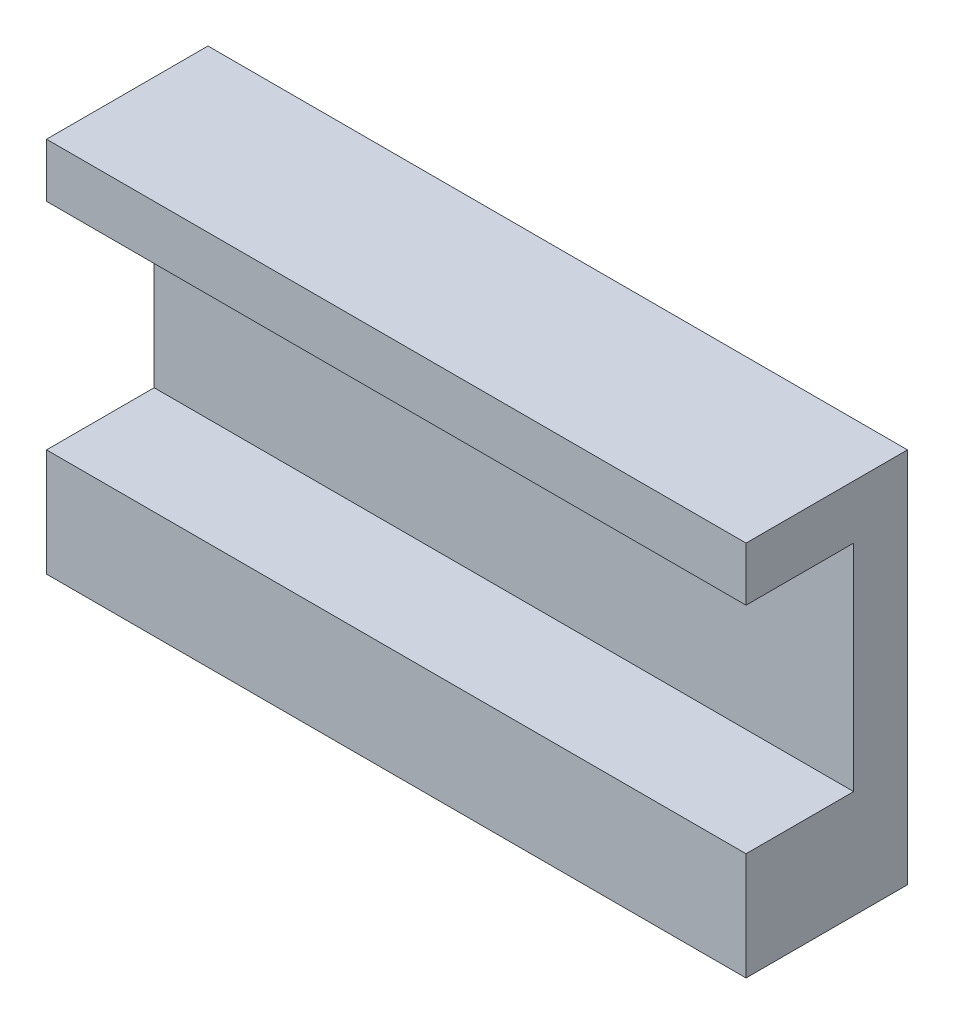
from build123d import *

# Parameters (mm, degrees)
SKETCH1_W           = 130
SKETCH1_H           = 70
BOSS_EXTRUDE1_DEPTH = 10
SKETCH2_W           = 130
SKETCH2_H           = 10
SKETCH2_H_2         = 20
BOSS_EXTRUDE2_DEPTH = 20


with BuildPart() as part:
    # Sketch1 → Boss-Extrude1 (new body)
    with BuildSketch(Plane.XY):
        with Locations((65, 35)):
            Rectangle(SKETCH1_W, SKETCH1_H)
    extrude(amount=BOSS_EXTRUDE1_DEPTH)

    # Sketch2 → Boss-Extrude2 (add)
    with BuildSketch(Plane.XY.offset(10)):
        with Locations((65, 65)):
            Rectangle(SKETCH2_W, SKETCH2_H)
        with Locations((65, 10)):
            Rectangle(SKETCH2_W, SKETCH2_H_2)
    extrude(amount=BOSS_EXTRUDE2_DEPTH)


solid = part.part
